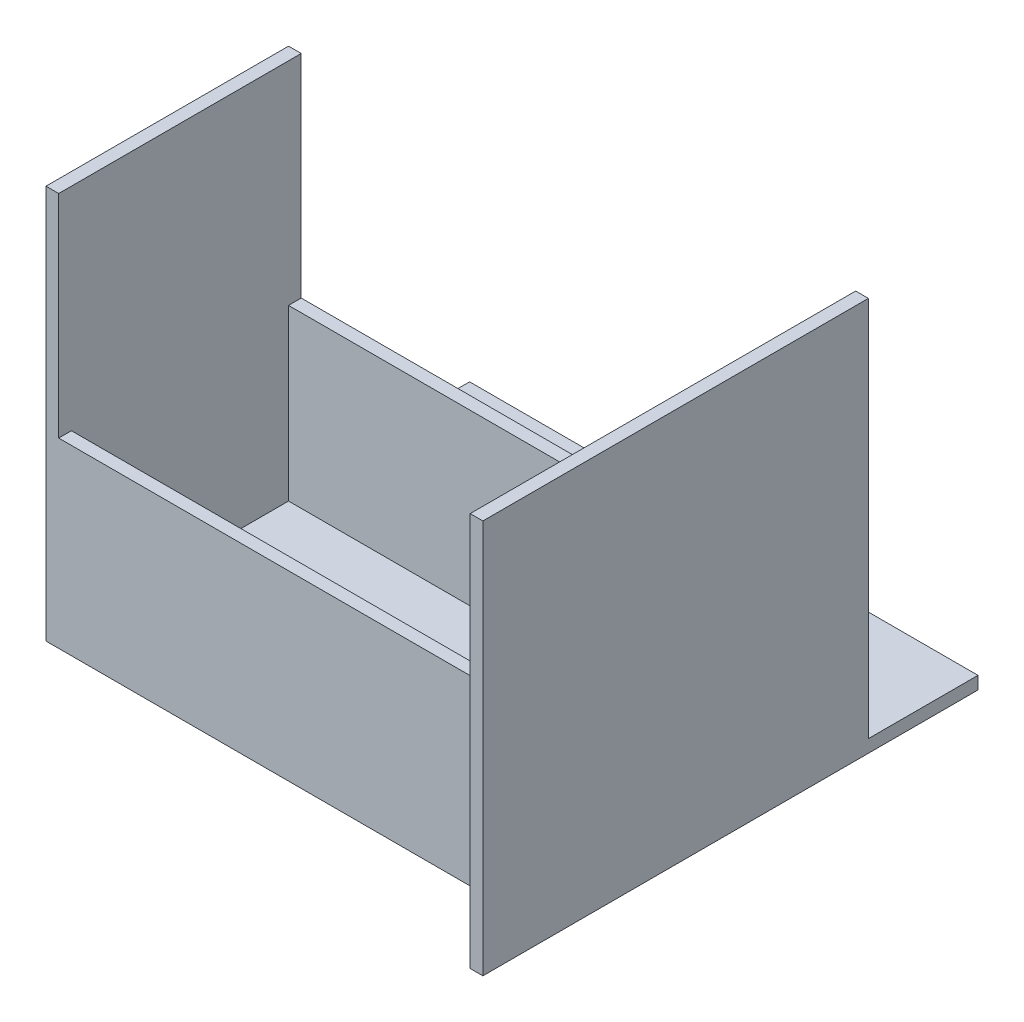
from build123d import *

# Parameters (mm, degrees)
SKETCH1_W           = 120
SKETCH1_H           = 100
BOSS_EXTRUDE1_DEPTH = 3
BOSS_EXTRUDE2_DEPTH = 40
SKETCH3_W           = 3
SKETCH3_H           = 57.25
BOSS_EXTRUDE3_DEPTH = 50
SKETCH4_W           = 3
SKETCH4_H           = 16.875
BOSS_EXTRUDE4_DEPTH = 93


with BuildPart() as part:
    # Sketch1 → Boss-Extrude1 (new body)
    with BuildSketch(Plane(origin=(0, 0, 0), x_dir=(1, 0, 0), z_dir=(0, 1, 0))):
        with Locations((60, 50)):
            Rectangle(SKETCH1_W, SKETCH1_H)
    extrude(amount=BOSS_EXTRUDE1_DEPTH)

    # Sketch2 → Boss-Extrude2 (add)
    with BuildSketch(Plane(origin=(0, 3, 0), x_dir=(1, 0, 0), z_dir=(0, 1, 0))):
        Polygon((117, 57.25), (0, 57.25), (0, 54.25), (3, 54.25), (117, 54.25), align=None)
        Polygon((3, 54.25), (0, 54.25), (0, 0), (3, 0), (3, 3), align=None)
        Polygon((120, 3), (117, 3), (3, 3), (3, 0), (120, 0), align=None)
        Polygon((120, 57.25), (117, 57.25), (117, 54.25), (117, 3), (120, 3), align=None)
    extrude(amount=BOSS_EXTRUDE2_DEPTH)

    # Sketch3 → Boss-Extrude3 (add)
    with BuildSketch(Plane(origin=(0, 43, 0), x_dir=(1, 0, 0), z_dir=(0, 1, 0))):
        with Locations((1.5, 28.625)):
            Rectangle(SKETCH3_W, SKETCH3_H)
    extrude(amount=BOSS_EXTRUDE3_DEPTH)

    # Sketch4 → Boss-Extrude4 (add)
    with BuildSketch(Plane.XZ):
        with Locations((118.5, 8.4375)):
            Rectangle(SKETCH4_W, SKETCH4_H)
        Polygon((120, -74.125), (120, 0), (117, 0), (117, -3), (117, -54.25), (117, -74.125), align=None)
    extrude(amount=-BOSS_EXTRUDE4_DEPTH)


solid = part.part
